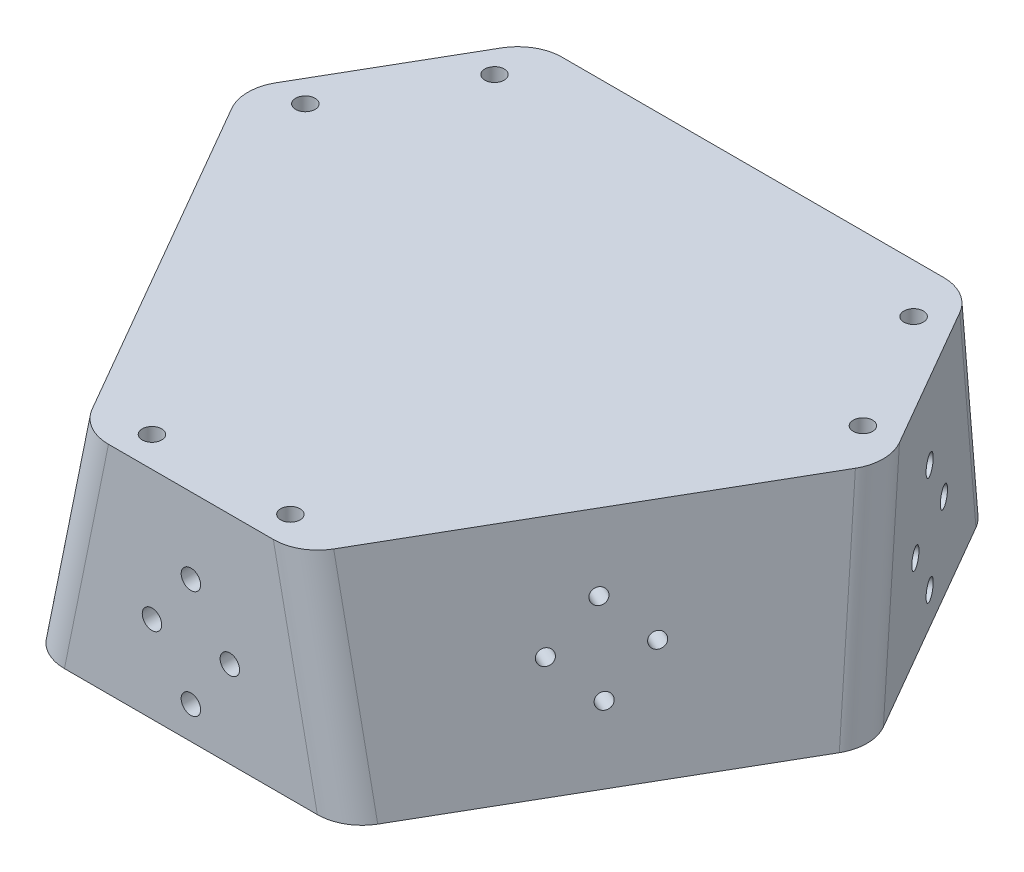
from build123d import *

# Parameters (mm, degrees)
BOSS_EXTRUDE1_DEPTH                           = 50
BOSS_EXTRUDE2_REACH                           = 77
BOSS_EXTRUDE2_DIRECTION_2_REACH               = 77
BOSS_EXTRUDE3_REACH                           = 97.135
BOSS_EXTRUDE3_DIRECTION_2_REACH               = 102
BOSS_EXTRUDE4_REACH                           = 97.135
BOSS_EXTRUDE4_DIRECTION_2_REACH               = 104.545
CUT_EXTRUDE1_DEPTH                            = 40
M3_CLEARANCE_HOLE1_AT_2_COUNT                 = 2
M3_CLEARANCE_HOLE1_AT_2_PITCH                 = 13.435028843
M3_CLEARANCE_HOLE1_AT_3_COUNT                 = 2
M3_CLEARANCE_HOLE1_AT_3_PITCH                 = 19
M3_CLEARANCE_HOLE1_AT_4_COUNT                 = 2
M3_CLEARANCE_HOLE1_AT_4_PITCH                 = 13.435028843
CIRPATTERN6_COUNT                             = 3
CUT_EXTRUDE2_DEPTH                            = 3.5
F_8_CLEARANCE_HOLE1_AT_2_COUNT                = 2
F_8_CLEARANCE_HOLE1_AT_2_PITCH                = 18
F_8_CLEARANCE_HOLE1_AT_3_COUNT                = 2
F_8_CLEARANCE_HOLE1_AT_3_PITCH                = 15.402921801
F_8_CLEARANCE_HOLE1_AT_4_COUNT                = 2
F_8_CLEARANCE_HOLE1_AT_4_PITCH                = 15.402921801
CBORE_FOR_8_SOCKET_HEAD_CAP_SCREW1_AT_2_COUNT = 2
CBORE_FOR_8_SOCKET_HEAD_CAP_SCREW1_AT_2_PITCH = 32
CIRPATTERN7_COUNT                             = 3
FILLET1_R                                     = 10


with BuildPart() as part:
    # Sketch1 → Boss-Extrude1 (new body)
    with BuildSketch(Plane(origin=(0, 0, 0), x_dir=(1, 0, 0), z_dir=(0, 1, 0))):
        Polygon((-50, 57.735026919), (50, 57.735026919), (75, 14.43375673), (25, -72.168783649), (-25, -72.168783649), (-75, 14.43375673), align=None)
    extrude(amount=BOSS_EXTRUDE1_DEPTH)

    # Boss-Extrude2: up to this face of the body (flat: up to its plane)
    boss_extrude2_end = Plane(part.part.faces().sort_by_distance((62.5, 25, -36.084391824))[0])
    # Sketch2 → Boss-Extrude2 (add, up to the picked face)
    with BuildSketch(Plane(origin=(0, 0, 0), x_dir=(0, 0, -1), z_dir=(1, 0, 0)), mode=Mode.PRIVATE) as boss_extrude2_sk1:
        Polygon((57.735026919, 50), (66.551375954, 0), (57.735026919, 0), align=None)
    boss_extrude2_tool1 = split(extrude(boss_extrude2_sk1.sketch, amount=BOSS_EXTRUDE2_REACH, mode=Mode.PRIVATE), bisect_by=boss_extrude2_end, keep=Keep.BOTH, mode=Mode.PRIVATE)
    add(boss_extrude2_tool1.solids().sort_by_distance((0, 16.666667, -60.67381))[0])

    # Boss-Extrude2 direction 2: up to this face of the body (flat: up to its plane)
    boss_extrude2_direction_2_end = Plane(part.part.faces().sort_by_distance((-62.5, 25, -36.084391824))[0])
    # Sketch2 → Boss-Extrude2 direction 2 (add, up to the picked face)
    with BuildSketch(Plane(origin=(0, 0, 0), x_dir=(0, 0, -1), z_dir=(1, 0, 0)), mode=Mode.PRIVATE) as boss_extrude2_direction_2_sk1:
        Polygon((57.735026919, 50), (66.551375954, 0), (57.735026919, 0), align=None)
    boss_extrude2_direction_2_tool1 = split(extrude(boss_extrude2_direction_2_sk1.sketch, amount=-BOSS_EXTRUDE2_DIRECTION_2_REACH, mode=Mode.PRIVATE), bisect_by=boss_extrude2_direction_2_end, keep=Keep.BOTH, mode=Mode.PRIVATE)
    add(boss_extrude2_direction_2_tool1.solids().sort_by_distance((0, 16.666667, -60.67381))[0])

    # Boss-Extrude3: up to this face of the body (flat: up to its plane)
    boss_extrude3_end = Plane(part.part.faces().sort_by_distance((-61.188277276, 24.230031121, -38.356362227))[0])
    # Sketch7 → Boss-Extrude3 (add, up to the picked face)
    with BuildSketch(Plane(origin=(0, 0, 0), x_dir=(-0.866025404, 0, 0.5), z_dir=(-0.5, 0, -0.866025404)), mode=Mode.PRIVATE) as boss_extrude3_sk1:
        Polygon((57.735026919, 50), (57.735026919, 0), (66.551375954, 0), align=None)
    boss_extrude3_tool1 = split(extrude(boss_extrude3_sk1.sketch, amount=BOSS_EXTRUDE3_REACH, mode=Mode.PRIVATE), bisect_by=boss_extrude3_end, keep=Keep.BOTH, mode=Mode.PRIVATE)
    add(boss_extrude3_tool1.solids().sort_by_distance((-52.545061, 16.666667, 30.336905))[0])

    # Boss-Extrude3 direction 2: up to this face of the body (flat: up to its plane)
    boss_extrude3_direction_2_end = Plane(part.part.faces().sort_by_distance((0, 25, 72.168783649))[0])
    # Sketch7 → Boss-Extrude3 direction 2 (add, up to the picked face)
    with BuildSketch(Plane(origin=(0, 0, 0), x_dir=(-0.866025404, 0, 0.5), z_dir=(-0.5, 0, -0.866025404)), mode=Mode.PRIVATE) as boss_extrude3_direction_2_sk1:
        Polygon((57.735026919, 50), (57.735026919, 0), (66.551375954, 0), align=None)
    boss_extrude3_direction_2_tool1 = split(extrude(boss_extrude3_direction_2_sk1.sketch, amount=-BOSS_EXTRUDE3_DIRECTION_2_REACH, mode=Mode.PRIVATE), bisect_by=boss_extrude3_direction_2_end, keep=Keep.BOTH, mode=Mode.PRIVATE)
    add(boss_extrude3_direction_2_tool1.solids().sort_by_distance((-52.545061, 16.666667, 30.336905))[0])

    # Boss-Extrude4: up to this face of the body (flat: up to its plane)
    boss_extrude4_end = Plane(part.part.faces().sort_by_distance((61.188277276, 24.230031121, -38.356362227))[0])
    # Sketch8 → Boss-Extrude4 (add, up to the picked face)
    with BuildSketch(Plane(origin=(0, 0, 0), x_dir=(-0.866025404, 0, -0.5), z_dir=(0.5, 0, -0.866025404)), mode=Mode.PRIVATE) as boss_extrude4_sk1:
        Polygon((-57.735026919, 50), (-57.735026919, 0), (-66.551375954, 0), align=None)
    boss_extrude4_tool1 = split(extrude(boss_extrude4_sk1.sketch, amount=BOSS_EXTRUDE4_REACH, mode=Mode.PRIVATE), bisect_by=boss_extrude4_end, keep=Keep.BOTH, mode=Mode.PRIVATE)
    add(boss_extrude4_tool1.solids().sort_by_distance((52.545061, 16.666667, 30.336905))[0])

    # Boss-Extrude4 direction 2: up to this face of the body (flat: up to its plane)
    boss_extrude4_direction_2_end = Plane(part.part.faces().sort_by_distance((-2.623445447, 24.230031121, 72.168783649))[0])
    # Sketch8 → Boss-Extrude4 direction 2 (add, up to the picked face)
    with BuildSketch(Plane(origin=(0, 0, 0), x_dir=(-0.866025404, 0, -0.5), z_dir=(0.5, 0, -0.866025404)), mode=Mode.PRIVATE) as boss_extrude4_direction_2_sk1:
        Polygon((-57.735026919, 50), (-57.735026919, 0), (-66.551375954, 0), align=None)
    boss_extrude4_direction_2_tool1 = split(extrude(boss_extrude4_direction_2_sk1.sketch, amount=-BOSS_EXTRUDE4_DIRECTION_2_REACH, mode=Mode.PRIVATE), bisect_by=boss_extrude4_direction_2_end, keep=Keep.BOTH, mode=Mode.PRIVATE)
    add(boss_extrude4_direction_2_tool1.solids().sort_by_distance((52.545061, 16.666667, 30.336905))[0])

    # Sketch9 → Cut-Extrude1 (cut)
    with BuildSketch(Plane.XZ):
        Polygon((-57.679491924, -14.43375673), (-41.339745962, -42.735026919), (41.339745962, -42.735026919), (57.679491924, -14.43375673), (16.339745962, 57.168783649), (-16.339745962, 57.168783649), align=None)
    extrude(amount=-CUT_EXTRUDE1_DEPTH, mode=Mode.SUBTRACT)

    # Sketch10 → M3 Clearance Hole1 (revolve, cut)
    with BuildSketch(Plane(origin=(0, 34.355673654, -60.493543749), x_dir=(0, 0.984807753, 0.173648178), z_dir=(1, 0, 0))):
        Polygon((0, 0), (0, 50), (1.7, 48.978536948), (1.7, 0), align=None)
    m3_clearance_hole1 = revolve(axis=Axis((0, 35.458339582, -66.74707298), (0, -0.173648178, 0.984807753)), mode=Mode.SUBTRACT)

    # M3 Clearance Hole1 at 2: M3 Clearance Hole1 ×2
    with Locations(*[Vector(0.707106781, -0.69636424, -0.122787804) * (i * M3_CLEARANCE_HOLE1_AT_2_PITCH) for i in range(1, M3_CLEARANCE_HOLE1_AT_2_COUNT)]):
        add(m3_clearance_hole1, mode=Mode.SUBTRACT)

    # M3 Clearance Hole1 at 3: M3 Clearance Hole1 ×2
    with Locations(*[Vector(0, -0.984807753, -0.173648178) * (i * M3_CLEARANCE_HOLE1_AT_3_PITCH) for i in range(1, M3_CLEARANCE_HOLE1_AT_3_COUNT)]):
        add(m3_clearance_hole1, mode=Mode.SUBTRACT)

    # M3 Clearance Hole1 at 4: M3 Clearance Hole1 ×2
    with Locations(*[Vector(-0.707106781, -0.69636424, -0.122787804) * (i * M3_CLEARANCE_HOLE1_AT_4_PITCH) for i in range(1, M3_CLEARANCE_HOLE1_AT_4_COUNT)]):
        add(m3_clearance_hole1, mode=Mode.SUBTRACT)

    # CirPattern6: M3 Clearance Hole1 ×3 about axis
    cirpattern6_axis = Axis((0, -2.5, 0), (0, 1, 0))
    for i in range(1, CIRPATTERN6_COUNT):
        add(m3_clearance_hole1.rotate(cirpattern6_axis, i * 360 / CIRPATTERN6_COUNT), mode=Mode.SUBTRACT)

    # CirPattern6 copy 1 sketch → CirPattern6 copy 1 (revolve, cut)
    with BuildSketch(Plane(origin=(-58.567591117, 25, 22.844359382), x_dir=(0.150383733, 0.984807753, -0.086824089), z_dir=(-0.5, 0, -0.866025404))):
        Polygon((0, 0), (0, 50), (1.7, 48.978536948), (1.7, 0), align=None)
    revolve(axis=Axis((-63.983306295, 26.102665928, 25.971123998), (0.852868532, -0.173648178, -0.492403877)), mode=Mode.SUBTRACT)

    # CirPattern6 copy 2 sketch → CirPattern6 copy 2 (revolve, cut)
    with BuildSketch(Plane(origin=(49.067591117, 25, 39.298842054), x_dir=(-0.150383733, 0.984807753, -0.086824089), z_dir=(-0.5, 0, 0.866025404))):
        Polygon((0, 0), (0, 50), (1.7, 48.978536948), (1.7, 0), align=None)
    revolve(axis=Axis((54.483306295, 26.102665928, 42.42560667), (-0.852868532, -0.173648178, -0.492403877)), mode=Mode.SUBTRACT)

    # CirPattern6 copy 3 sketch → CirPattern6 copy 3 (revolve, cut)
    with BuildSketch(Plane(origin=(-55.246236582, 15.644326346, 31.896429562), x_dir=(0.150383733, 0.984807753, -0.086824089), z_dir=(-0.5, 0, -0.866025404))):
        Polygon((0, 0), (0, 50), (1.7, 48.978536948), (1.7, 0), align=None)
    revolve(axis=Axis((-60.66195176, 16.746992275, 35.023194178), (0.852868532, -0.173648178, -0.492403877)), mode=Mode.SUBTRACT)

    # CirPattern6 copy 4 sketch → CirPattern6 copy 4 (revolve, cut)
    with BuildSketch(Plane(origin=(55.246236582, 15.644326346, 31.896429562), x_dir=(-0.150383733, 0.984807753, -0.086824089), z_dir=(-0.5, 0, 0.866025404))):
        Polygon((0, 0), (0, 50), (1.7, 48.978536948), (1.7, 0), align=None)
    revolve(axis=Axis((60.66195176, 16.746992275, 35.023194178), (-0.852868532, -0.173648178, -0.492403877)), mode=Mode.SUBTRACT)

    # CirPattern6 copy 5 sketch → CirPattern6 copy 5 (revolve, cut)
    with BuildSketch(Plane(origin=(-49.067591117, 25, 39.298842054), x_dir=(0.150383733, 0.984807753, -0.086824089), z_dir=(-0.5, 0, -0.866025404))):
        Polygon((0, 0), (0, 50), (1.7, 48.978536948), (1.7, 0), align=None)
    revolve(axis=Axis((-54.483306295, 26.102665928, 42.42560667), (0.852868532, -0.173648178, -0.492403877)), mode=Mode.SUBTRACT)

    # CirPattern6 copy 6 sketch → CirPattern6 copy 6 (revolve, cut)
    with BuildSketch(Plane(origin=(58.567591117, 25, 22.844359382), x_dir=(-0.150383733, 0.984807753, -0.086824089), z_dir=(-0.5, 0, 0.866025404))):
        Polygon((0, 0), (0, 50), (1.7, 48.978536948), (1.7, 0), align=None)
    revolve(axis=Axis((63.983306295, 26.102665928, 25.971123998), (-0.852868532, -0.173648178, -0.492403877)), mode=Mode.SUBTRACT)

    # Sketch12 → Cut-Extrude2 (cut)
    with BuildSketch(Plane(origin=(-49.509618943, 0, -28.584391824), x_dir=(0.5, 0, -0.866025404), z_dir=(0.866025404, 0, 0.5))):
        Polygon((-4.525, 17.416357545), (-4.525, 22.583642455), (-9, 25.167284909), (-13.475, 22.583642455), (-13.475, 17.416357545), (-9, 14.832715091), align=None)
        Polygon((9, 14.832715091), (13.475, 17.416357545), (13.475, 22.583642455), (9, 25.167284909), (4.525, 22.583642455), (4.525, 17.416357545), align=None)
        Polygon((4.475, 4.916357545), (4.475, 10.083642455), (0, 12.667284909), (-4.475, 10.083642455), (-4.475, 4.916357545), (0, 2.332715091), align=None)
        Polygon((4.475, 29.916357545), (4.475, 35.083642455), (0, 37.667284909), (-4.475, 35.083642455), (-4.475, 29.916357545), (0, 27.332715091), align=None)
    cut_extrude2 = extrude(amount=-CUT_EXTRUDE2_DEPTH, mode=Mode.SUBTRACT)

    # Sketch14 → 8 Clearance Hole1 (revolve, cut)
    with BuildSketch(Plane(origin=(-57.040707856, 20, -22.54016319), x_dir=(0.5, 0, -0.866025404), z_dir=(0, 1, 0))):
        Polygon((0, 0), (0, 50), (2.2479, 48.649325414), (2.2479, 0), align=None)
    f_8_clearance_hole1 = revolve(axis=Axis((-51.541446542, 20, -19.36516319), (-0.866025404, 0, -0.5)), mode=Mode.SUBTRACT)

    # 8 Clearance Hole1 at 2: 8 Clearance Hole1 ×2
    with Locations(*[Vector(0.5, 0, -0.866025404) * (i * F_8_CLEARANCE_HOLE1_AT_2_PITCH) for i in range(1, F_8_CLEARANCE_HOLE1_AT_2_COUNT)]):
        add(f_8_clearance_hole1, mode=Mode.SUBTRACT)

    # 8 Clearance Hole1 at 3: 8 Clearance Hole1 ×2
    with Locations(*[Vector(0.292152363, -0.811534341, -0.506022736) * (i * F_8_CLEARANCE_HOLE1_AT_3_PITCH) for i in range(1, F_8_CLEARANCE_HOLE1_AT_3_COUNT)]):
        add(f_8_clearance_hole1, mode=Mode.SUBTRACT)

    # 8 Clearance Hole1 at 4: 8 Clearance Hole1 ×2
    with Locations(*[Vector(0.292152363, 0.811534341, -0.506022736) * (i * F_8_CLEARANCE_HOLE1_AT_4_PITCH) for i in range(1, F_8_CLEARANCE_HOLE1_AT_4_COUNT)]):
        add(f_8_clearance_hole1, mode=Mode.SUBTRACT)

    # Sketch19 → CBORE for _8 Socket Head Cap Screw1 (revolve, cut)
    with BuildSketch(Plane(origin=(-64.437822174, 0, -18.727985364), x_dir=(0, 0, -1), z_dir=(1, 0, 0))):
        Polygon((0, 0), (0, 60), (2.2479, 58.649325414), (2.2479, 12.7), (3.96875, 12.7), (3.96875, 0), align=None)
    cbore_for_8_socket_head_cap_screw1 = revolve(axis=Axis((-64.437822174, -6.35, -18.727985364), (0, 1, 0)), mode=Mode.SUBTRACT)

    # CBORE for _8 Socket Head Cap Screw1 at 2: CBORE for _8 Socket Head Cap Screw1 ×2
    with Locations(*[Vector(0.5, 0, -0.866025404) * (i * CBORE_FOR_8_SOCKET_HEAD_CAP_SCREW1_AT_2_PITCH) for i in range(1, CBORE_FOR_8_SOCKET_HEAD_CAP_SCREW1_AT_2_COUNT)]):
        add(cbore_for_8_socket_head_cap_screw1, mode=Mode.SUBTRACT)

    # CirPattern7: 8 Clearance Hole1, Cut-Extrude2, CBORE for _8 Socket Head Cap Screw1 ×3 about axis
    cirpattern7_axis = Axis((0, 0, 0), (0, 1, 0))
    for i in range(1, CIRPATTERN7_COUNT):
        add(f_8_clearance_hole1.rotate(cirpattern7_axis, i * 360 / CIRPATTERN7_COUNT), mode=Mode.SUBTRACT)
        add(cut_extrude2.rotate(cirpattern7_axis, i * 360 / CIRPATTERN7_COUNT), mode=Mode.SUBTRACT)
        add(cbore_for_8_socket_head_cap_screw1.rotate(cirpattern7_axis, i * 360 / CIRPATTERN7_COUNT), mode=Mode.SUBTRACT)

    # CirPattern7 copy 1 sketch → CirPattern7 copy 1 (revolve, cut)
    with BuildSketch(Plane(origin=(-9, 20, 60.668783649), x_dir=(-1, 0, 0), z_dir=(0, 1, 0))):
        Polygon((0, 0), (0, 50), (2.2479, 48.649325414), (2.2479, 0), align=None)
    revolve(axis=Axis((-9, 20, 54.318783649), (0, 0, 1)), mode=Mode.SUBTRACT)

    # CirPattern7 copy 2 sketch → CirPattern7 copy 2 (revolve, cut)
    with BuildSketch(Plane(origin=(57.040707856, 20, -22.54016319), x_dir=(0.5, 0, 0.866025404), z_dir=(0, 1, 0))):
        Polygon((0, 0), (0, 50), (2.2479, 48.649325414), (2.2479, 0), align=None)
    revolve(axis=Axis((51.541446542, 20, -19.36516319), (0.866025404, 0, -0.5)), mode=Mode.SUBTRACT)

    # CirPattern7 copy 3 sketch → CirPattern7 copy 3 (revolve, cut)
    with BuildSketch(Plane(origin=(0, 7.5, 60.668783649), x_dir=(-1, 0, 0), z_dir=(0, 1, 0))):
        Polygon((0, 0), (0, 50), (2.2479, 48.649325414), (2.2479, 0), align=None)
    revolve(axis=Axis((0, 7.5, 54.318783649), (0, 0, 1)), mode=Mode.SUBTRACT)

    # CirPattern7 copy 4 sketch → CirPattern7 copy 4 (revolve, cut)
    with BuildSketch(Plane(origin=(52.540707856, 7.5, -30.334391824), x_dir=(0.5, 0, 0.866025404), z_dir=(0, 1, 0))):
        Polygon((0, 0), (0, 50), (2.2479, 48.649325414), (2.2479, 0), align=None)
    revolve(axis=Axis((47.041446542, 7.5, -27.159391824), (0.866025404, 0, -0.5)), mode=Mode.SUBTRACT)

    # CirPattern7 copy 5 sketch → CirPattern7 copy 5 (revolve, cut)
    with BuildSketch(Plane(origin=(0, 32.5, 60.668783649), x_dir=(-1, 0, 0), z_dir=(0, 1, 0))):
        Polygon((0, 0), (0, 50), (2.2479, 48.649325414), (2.2479, 0), align=None)
    revolve(axis=Axis((0, 32.5, 54.318783649), (0, 0, 1)), mode=Mode.SUBTRACT)

    # CirPattern7 copy 6 sketch → CirPattern7 copy 6 (revolve, cut)
    with BuildSketch(Plane(origin=(52.540707856, 32.5, -30.334391824), x_dir=(0.5, 0, 0.866025404), z_dir=(0, 1, 0))):
        Polygon((0, 0), (0, 50), (2.2479, 48.649325414), (2.2479, 0), align=None)
    revolve(axis=Axis((47.041446542, 32.5, -27.159391824), (0.866025404, 0, -0.5)), mode=Mode.SUBTRACT)

    # CirPattern7 copy 7 sketch → CirPattern7 copy 7 (revolve, cut)
    with BuildSketch(Plane(origin=(-16, 0, 65.168783649), x_dir=(-0.866025404, 0, 0.5), z_dir=(-0.5, 0, -0.866025404))):
        Polygon((0, 0), (0, 60), (2.2479, 58.649325414), (2.2479, 12.7), (3.96875, 12.7), (3.96875, 0), align=None)
    revolve(axis=Axis((-16, -6.35, 65.168783649), (0, 1, 0)), mode=Mode.SUBTRACT)

    # CirPattern7 copy 8 sketch → CirPattern7 copy 8 (revolve, cut)
    with BuildSketch(Plane(origin=(64.437822174, 0, -18.727985364), x_dir=(0.866025404, 0, 0.5), z_dir=(-0.5, 0, 0.866025404))):
        Polygon((0, 0), (0, 60), (2.2479, 58.649325414), (2.2479, 12.7), (3.96875, 12.7), (3.96875, 0), align=None)
    revolve(axis=Axis((64.437822174, -6.35, -18.727985364), (0, 1, 0)), mode=Mode.SUBTRACT)

    # Fillet1
    fillet1_edges = [part.edges().sort_by_distance(p)[0] for p in [
        (47.454939256, 25, -62.143201437),
        (-47.454939256, 25, -62.143201437),
        (-77.545060744, 25, -10.025582212),
        (-30.090121489, 25, 72.168783649),
        (77.545060744, 25, -10.025582212),
        (30.090121489, 25, 72.168783649),
    ]]
    fillet(fillet1_edges, radius=FILLET1_R)


solid = part.part
